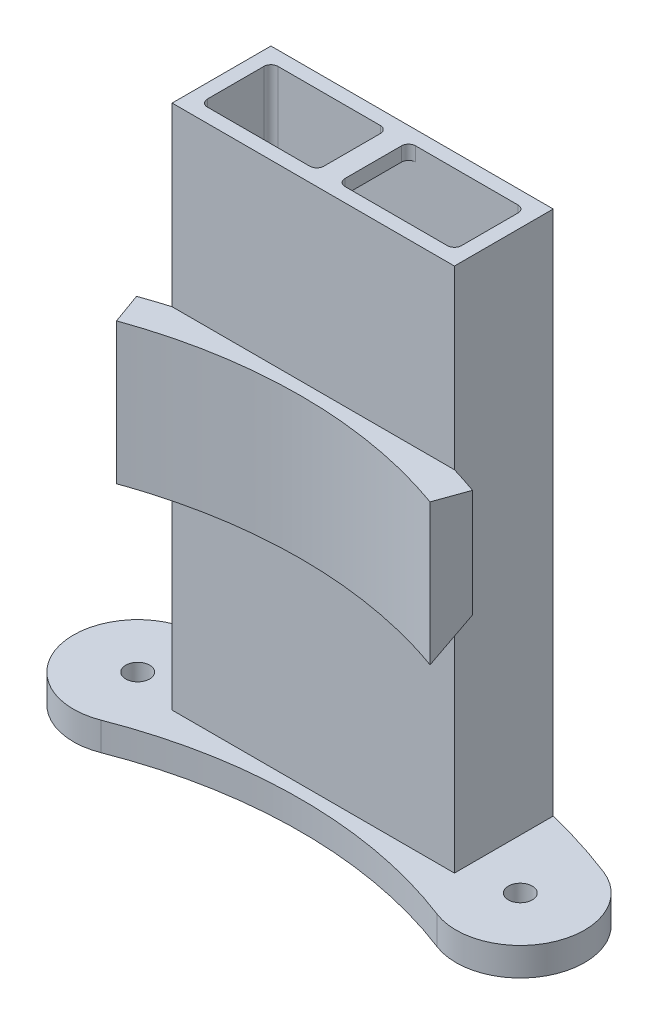
from build123d import *

# Parameters (mm, degrees)
SKETCH1_W                    = 40
SKETCH1_H                    = 14
SKETCH1_W_2                  = 36
SKETCH1_H_2                  = 10
BOSS_EXTRUDE1_DEPTH          = 78.5
SKETCH2_W                    = 3
SKETCH2_H                    = 10
BOSS_EXTRUDE2_DEPTH          = 2
BOSS_EXTRUDE7_START          = -25
BOSS_EXTRUDE7_DEPTH          = 20
CUT_REVOLVE1_ANGLE           = 323.76
CUT_REVOLVE1_OTHER_WAY_ANGLE = 3.31
SKETCH20_R                   = 1.7
BOSS_EXTRUDE8_DEPTH          = 4
FILLET1_R                    = 1


with BuildPart() as part:
    # Sketch1 → Boss-Extrude1 (new body)
    with BuildSketch(Plane(origin=(0, 0, 0), x_dir=(1, 0, 0), z_dir=(0, 1, 0))):
        with Locations((18, 5)):
            Rectangle(SKETCH1_W, SKETCH1_H)
        with Locations((18, 5)):
            Rectangle(SKETCH1_W_2, SKETCH1_H_2, mode=Mode.SUBTRACT)
    extrude(amount=BOSS_EXTRUDE1_DEPTH)

    # Sketch2 → Boss-Extrude2 (add)
    with BuildSketch(Plane(origin=(0, 78.5, 0), x_dir=(1, 0, 0), z_dir=(0, 1, 0))):
        with Locations((18, 5)):
            Rectangle(SKETCH2_W, SKETCH2_H)
    extrude(amount=-BOSS_EXTRUDE2_DEPTH)

    # Sketch17 → Boss-Extrude7 (add)
    with BuildSketch(Plane(origin=(0, 78.5, 0), x_dir=(1, 0, 0), z_dir=(0, 1, 0)).offset(BOSS_EXTRUDE7_START)):
        with BuildLine():
            Line((-4.214182636, -7.666297866), (-5.801637028, -3.244008002))
            ThreePointArc((-5.801637028, -3.244008002), (-3.909649485, -2.595016918), (-2, -2))
            Line((-2, -2), (38, -2))
            ThreePointArc((38, -2), (39.909649485, -2.595016918), (41.801637028, -3.244008002))
            Line((41.801637028, -3.244008002), (40.214182636, -7.666297866))
            ThreePointArc((40.214182636, -7.666297866), (18, -3.8), (-4.214182636, -7.666297866))
        make_face()
    extrude(amount=-BOSS_EXTRUDE7_DEPTH)

    # Sketch19 → Cut-Revolve1 (revolve, cut)
    with BuildSketch(Plane(origin=(-6.170956479, 0, 2.215167315), x_dir=(0.337858291, 0, 0.941196991), z_dir=(-0.941196991, 0, 0.337858291))):
        Polygon((1.093119398, 38.198580539), (5.791699937, 33.5), (1.093119398, 33.5), align=None)
    revolve(axis=Axis((18, 33.5, 69.55), (0, 1, 0)), revolution_arc=CUT_REVOLVE1_ANGLE, mode=Mode.SUBTRACT)

    # Sketch19 → Cut-Revolve1 other way (revolve, cut)
    with BuildSketch(Plane(origin=(-6.170956479, 0, 2.215167315), x_dir=(0.337858291, 0, 0.941196991), z_dir=(-0.941196991, 0, 0.337858291))):
        Polygon((1.093119398, 38.198580539), (5.791699937, 33.5), (1.093119398, 33.5), align=None)
    revolve(axis=Axis((18, 33.5, 69.55), (0, -1, 0)), revolution_arc=CUT_REVOLVE1_OTHER_WAY_ANGLE, mode=Mode.SUBTRACT)

    # Fillet1
    fillet1_edges = [part.edges().sort_by_distance(p)[0] for p in [
        (0, 39.25, -10),
        (0, 39.25, 0),
        (36, 39.25, 0),
        (36, 39.25, -10),
        (19.5, 77.5, -10),
        (19.5, 77.5, 0),
        (16.5, 77.5, 0),
        (16.5, 77.5, -10),
    ]]
    fillet(fillet1_edges, radius=FILLET1_R)


with BuildPart() as body_2:
    # Sketch20 → Boss-Extrude8 (new body)
    with BuildSketch(Plane.XZ):
        with BuildLine():
            ThreePointArc((38, -12), (43.256739188, -10.528084552), (48.406726055, -8.717704135))
            ThreePointArc((48.406726055, -8.717704135), (53.598475523, 3.070822505), (41.809948883, 8.262571973))
            ThreePointArc((41.809948883, 8.262571973), (18, 3.8), (-5.809948883, 8.262571973))
            ThreePointArc((-5.809948883, 8.262571973), (-17.598475523, 3.070822505), (-12.406726055, -8.717704135))
            ThreePointArc((-12.406726055, -8.717704135), (-7.256739188, -10.528084552), (-2, -12))
            Line((-2, -12), (-2, 2))
            Line((-2, 2), (38, 2))
            Line((38, 2), (38, -12))
        make_face()
        with Locations((-9.108337469, -0.227566081)):
            Circle(SKETCH20_R, mode=Mode.SUBTRACT)
        with Locations((45.108337469, -0.227566081)):
            Circle(SKETCH20_R, mode=Mode.SUBTRACT)
    extrude(amount=-BOSS_EXTRUDE8_DEPTH)


solid = Compound([part.part, body_2.part])
